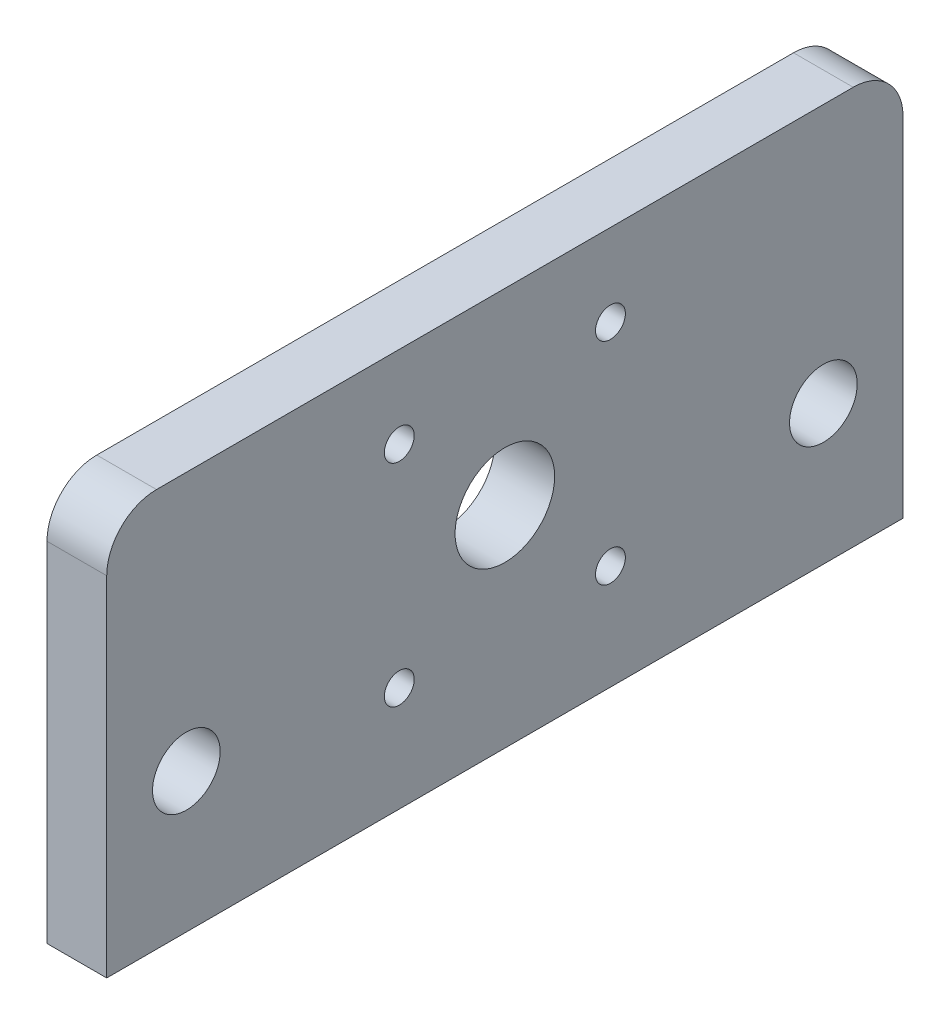
from build123d import *

# Parameters (mm, degrees)
SKETCH3_W           = 80
SKETCH3_H           = 40
BOSS_EXTRUDE3_DEPTH = 6
SKETCH4_R           = 5
SKETCH4_R_2         = 1.5
SKETCH4_R_3         = 3.4
CUT_EXTRUDE1_DEPTH  = 8
FILLET1_R           = 5


with BuildPart() as part:
    # Sketch3 → Boss-Extrude3 (new body)
    with BuildSketch(Plane(origin=(0, 0, 0), x_dir=(0, 0, -1), z_dir=(1, 0, 0))):
        Rectangle(SKETCH3_W, SKETCH3_H)
    extrude(amount=-BOSS_EXTRUDE3_DEPTH)

    # Sketch4 → Cut-Extrude1 (cut)
    with BuildSketch(Plane(origin=(0, 0, 0), x_dir=(0, 0, -1), z_dir=(1, 0, 0))):
        with Locations((0, 1.15)):
            Circle(SKETCH4_R)
        with Locations((-10.606601718, 11.756601718)):
            Circle(SKETCH4_R_2)
        with Locations((10.606601718, 11.756601718)):
            Circle(SKETCH4_R_2)
        with Locations((10.606601718, -9.456601718)):
            Circle(SKETCH4_R_2)
        with Locations((-10.606601718, -9.456601718)):
            Circle(SKETCH4_R_2)
        with Locations((32, -6)):
            Circle(SKETCH4_R_3)
        with Locations((-32, -6)):
            Circle(SKETCH4_R_3)
    extrude(amount=-CUT_EXTRUDE1_DEPTH, mode=Mode.SUBTRACT)

    # Fillet1
    fillet1_edges = [part.edges().sort_by_distance(p)[0] for p in [
        (-3, 20, 40),
        (-3, 20, -40),
    ]]
    fillet(fillet1_edges, radius=FILLET1_R)


solid = part.part
